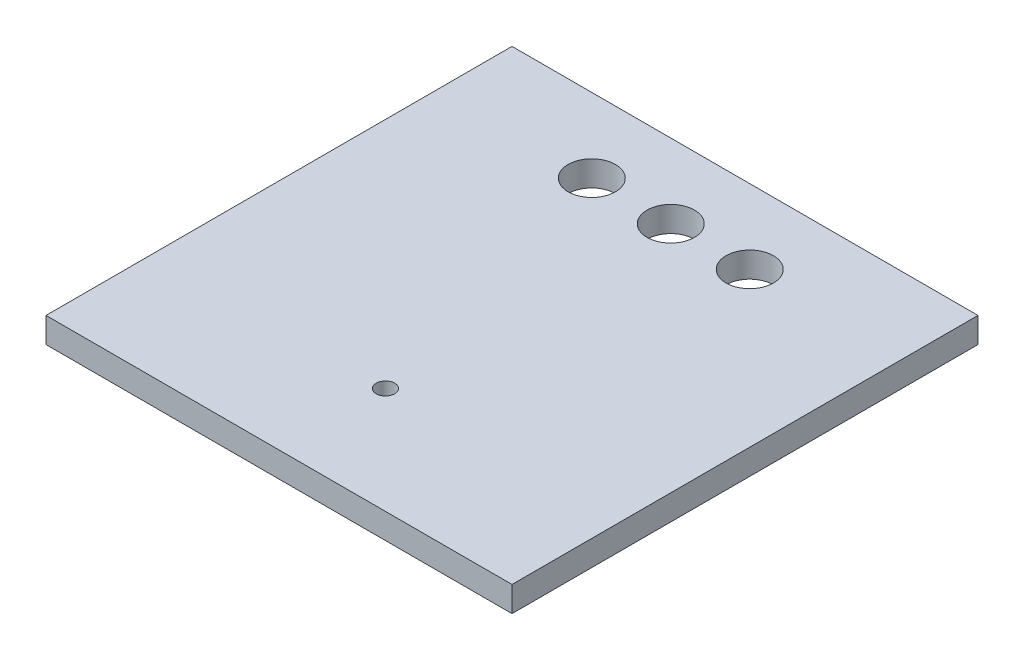
from build123d import *

# Parameters (mm, degrees)
SKETCH1_W           = 14.986
SKETCH1_H           = 14.986
BOSS_EXTRUDE1_DEPTH = 0.8128
SKETCH2_R           = 0.762
SKETCH2_R_2         = 0.297244981
CUT_EXTRUDE1_DEPTH  = 8.4328


with BuildPart() as part:
    # Sketch1 → Boss-Extrude1 (new body)
    with BuildSketch(Plane(origin=(0, 0, 0), x_dir=(1, 0, 0), z_dir=(0, 1, 0))):
        Rectangle(SKETCH1_W, SKETCH1_H)
    extrude(amount=BOSS_EXTRUDE1_DEPTH)

    # Sketch2 → Cut-Extrude1 (cut)
    with BuildSketch(Plane(origin=(0, 2.54, 0), x_dir=(1, 0, 0), z_dir=(0, 1, 0))):
        with Locations((0, 5.10575448)):
            Circle(SKETCH2_R)
        with Locations((-2.54, 5.10575448)):
            Circle(SKETCH2_R)
        with Locations((2.54, 5.10575448)):
            Circle(SKETCH2_R)
        with Locations((0, -4.070202077)):
            Circle(SKETCH2_R_2)
    extrude(amount=-CUT_EXTRUDE1_DEPTH, mode=Mode.SUBTRACT)


solid = part.part
